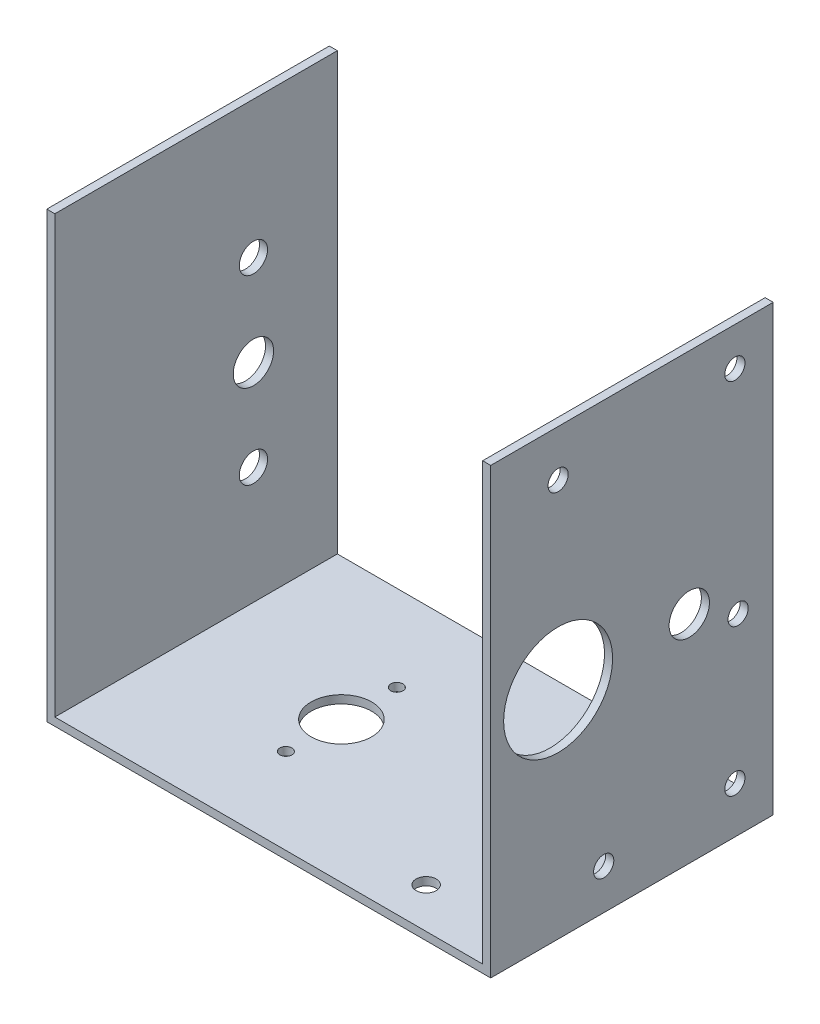
from build123d import *

# Parameters (mm, degrees)
ESBO_O1_W                = 110
ESBO_O1_H                = 70
RESSALTO_EXTRUS_O1_DEPTH = 2
ESBO_O2_W                = 70
ESBO_O2_H                = 110
RESSALTO_EXTRUS_O2_DEPTH = 2
ESBO_O3_W                = 70
ESBO_O3_H                = 110
RESSALTO_EXTRUS_O3_DEPTH = 2
ESBO_O4_R                = 7.5
CORTE_EXTRUS_O1_DEPTH    = 6.35
ESBO_O5_R                = 2.5
CORTE_EXTRUS_O2_DEPTH    = 10
ESBO_O6_R                = 2.5
CORTE_EXTRUS_O3_DEPTH    = 10
ESBO_O7_R                = 13.5
ESBO_O7_R_2              = 1
CORTE_EXTRUS_O5_DEPTH    = 10
ESBO_O9_R                = 5
CORTE_EXTRUS_O6_DEPTH    = 160.452187191
ESBO_O10_R               = 2.5
CORTE_EXTRUS_O7_DEPTH    = 2
CORTE_EXTRUS_O11_REACH   = 128.151
ESBO_O18_R               = 2.5
ESBO_O19_R               = 1.5
CORTE_EXTRUS_O12_DEPTH   = 10
CORTE_EXTRUS_O13_REACH   = 161.452


with BuildPart() as part:
    # Esboço1 → Ressalto-extrusão1 (new body)
    with BuildSketch(Plane(origin=(0, 0, 0), x_dir=(1, 0, 0), z_dir=(0, 1, 0))):
        Rectangle(ESBO_O1_W, ESBO_O1_H)
    extrude(amount=RESSALTO_EXTRUS_O1_DEPTH)

    # Esboço2 → Ressalto-extrusão2 (add)
    with BuildSketch(Plane.ZY.offset(55)):
        with Locations((0, 55)):
            Rectangle(ESBO_O2_W, ESBO_O2_H)
    extrude(amount=-RESSALTO_EXTRUS_O2_DEPTH)

    # Esboço3 → Ressalto-extrusão3 (add)
    with BuildSketch(Plane(origin=(55, 0, 0), x_dir=(0, 0, -1), z_dir=(1, 0, 0))):
        with Locations((0, 55)):
            Rectangle(ESBO_O3_W, ESBO_O3_H)
    extrude(amount=-RESSALTO_EXTRUS_O3_DEPTH)

    # Esboço4 → Corte-extrusão1 (cut)
    with BuildSketch(Plane(origin=(0, 2, 0), x_dir=(1, 0, 0), z_dir=(0, 1, 0))):
        with Locations(Location((-17, 0, 0), (0, 0, 270))):
            Circle(ESBO_O4_R)
    extrude(amount=-CORTE_EXTRUS_O1_DEPTH, mode=Mode.SUBTRACT)

    # Esboço5 → Corte-extrusão2 (cut)
    with BuildSketch(Plane(origin=(55, 0, 0), x_dir=(0, 0, -1), z_dir=(1, 0, 0))):
        with Locations((-7, 10)):
            Circle(ESBO_O5_R)
    extrude(amount=-CORTE_EXTRUS_O2_DEPTH, mode=Mode.SUBTRACT)

    # Esboço6 → Corte-extrusão3 (cut)
    with BuildSketch(Plane(origin=(55, 0, 0), x_dir=(0, 0, -1), z_dir=(1, 0, 0))):
        with Locations((-18.3, 98.5)):
            Circle(ESBO_O6_R)
        with Locations((26.3, 47.5)):
            Circle(ESBO_O6_R)
    extrude(amount=-CORTE_EXTRUS_O3_DEPTH, mode=Mode.SUBTRACT)

    # Esboço7 → Corte-extrusão5 (cut)
    with BuildSketch(Plane.ZY.offset(-53)):
        with Locations((18.3, 53.5)):
            Circle(ESBO_O7_R)
        with Locations((18.3, 53.5)):
            Circle(ESBO_O7_R_2, mode=Mode.SUBTRACT)
        with Locations((18.3, 53.5)):
            Circle(ESBO_O7_R_2)
    extrude(amount=-CORTE_EXTRUS_O5_DEPTH, mode=Mode.SUBTRACT)

    # Esboço9 → Corte-extrusão6 (cut, through all)
    with BuildSketch(Plane(origin=(55, 0, 0), x_dir=(0, 0, -1), z_dir=(1, 0, 0))):
        with Locations((14.2, 53.5)):
            Circle(ESBO_O9_R)
    extrude(amount=-CORTE_EXTRUS_O6_DEPTH, mode=Mode.SUBTRACT)

    # Esboço10 → Corte-extrusão7 (cut)
    with BuildSketch(Plane(origin=(55, 0, 0), x_dir=(0, 0, -1), z_dir=(1, 0, 0))):
        with Locations((25.5, 11.5)):
            Circle(ESBO_O10_R)
        with Locations((25.5, 100.5)):
            Circle(ESBO_O10_R)
    extrude(amount=-CORTE_EXTRUS_O7_DEPTH, mode=Mode.SUBTRACT)

    # Esboço18 → Corte-extrusão11 (cut, up to next)
    with BuildSketch(Plane(origin=(0, 2, 0), x_dir=(1, 0, 0), z_dir=(0, 1, 0)), mode=Mode.PRIVATE) as corte_extrus_o11_sk1:
        with Locations(Location((29, 25, 0), (0, 0, 270))):
            Circle(ESBO_O18_R)
    corte_extrus_o11_tool1 = extrude(corte_extrus_o11_sk1.sketch, amount=-CORTE_EXTRUS_O11_REACH, mode=Mode.PRIVATE) & part.part
    # Esboço18 → Corte-extrusão11 (cut, up to next)
    with BuildSketch(Plane(origin=(0, 2, 0), x_dir=(1, 0, 0), z_dir=(0, 1, 0)), mode=Mode.PRIVATE) as corte_extrus_o11_sk2:
        with Locations(Location((29, -25, 0), (0, 0, 270))):
            Circle(ESBO_O18_R)
    corte_extrus_o11_tool2 = extrude(corte_extrus_o11_sk2.sketch, amount=-CORTE_EXTRUS_O11_REACH, mode=Mode.PRIVATE) & part.part
    add(corte_extrus_o11_tool1.solids().sort_by_distance((29, 2, -25))[0], mode=Mode.SUBTRACT)
    add(corte_extrus_o11_tool2.solids().sort_by_distance((29, 2, 25))[0], mode=Mode.SUBTRACT)

    # Esboço19 → Corte-extrusão12 (cut)
    with BuildSketch(Plane(origin=(0, 2, 0), x_dir=(1, 0, 0), z_dir=(0, 1, 0))):
        with Locations(Location((-17, 13.75, 0), (0, 0, 270))):
            Circle(ESBO_O19_R)
        with Locations(Location((-17, -13.75, 0), (0, 0, 270))):
            Circle(ESBO_O19_R)
    extrude(amount=-CORTE_EXTRUS_O12_DEPTH, mode=Mode.SUBTRACT)

    # Esboço20 → Corte-extrusão13 (cut, up to next)
    with BuildSketch(Plane.ZY.offset(55), mode=Mode.PRIVATE) as corte_extrus_o13_sk1:
        with BuildLine():
            ThreePointArc((-17.7, 31), (-14.2, 27.5), (-10.7, 31))
            ThreePointArc((-10.7, 31), (-14.2, 34.5), (-17.7, 31))
        make_face()
    corte_extrus_o13_tool1 = extrude(corte_extrus_o13_sk1.sketch, amount=-CORTE_EXTRUS_O13_REACH, mode=Mode.PRIVATE) & part.part
    # Esboço20 → Corte-extrusão13 (cut, up to next)
    with BuildSketch(Plane.ZY.offset(55), mode=Mode.PRIVATE) as corte_extrus_o13_sk2:
        with BuildLine():
            ThreePointArc((-17.7, 76), (-14.2, 72.5), (-10.7, 76))
            ThreePointArc((-10.7, 76), (-14.2, 79.5), (-17.7, 76))
        make_face()
    corte_extrus_o13_tool2 = extrude(corte_extrus_o13_sk2.sketch, amount=-CORTE_EXTRUS_O13_REACH, mode=Mode.PRIVATE) & part.part
    add(corte_extrus_o13_tool1.solids().sort_by_distance((-55, 31, -14.2))[0], mode=Mode.SUBTRACT)
    add(corte_extrus_o13_tool2.solids().sort_by_distance((-55, 76, -14.2))[0], mode=Mode.SUBTRACT)


solid = part.part
